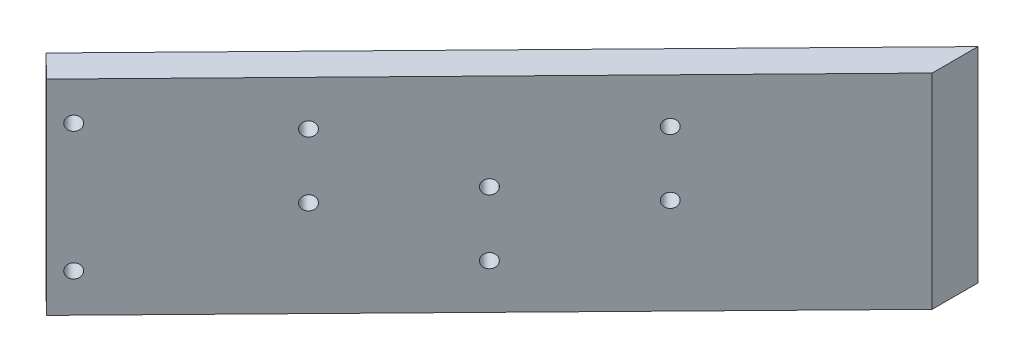
from build123d import *

# Parameters (mm, degrees)
BOSS_EXTRUDE1_DEPTH = 32
FILLET1_R           = 10
SKETCH4_W           = 170.11041037
SKETCH4_H           = 258.008077424
CUT_EXTRUDE2_DEPTH  = 33
SKETCH6_R           = 1.1
CUT_EXTRUDE3_DEPTH  = 54.954614149
SKETCH7_R           = 1.1
CUT_EXTRUDE4_DEPTH  = 57.514129524


with BuildPart() as part:
    # Sketch1 → Boss-Extrude1 (new body)
    with BuildSketch(Plane(origin=(0, 0, 0), x_dir=(1, 0, 0), z_dir=(0, 1, 0))):
        Polygon((0, 0), (0, 30), (83, 115), (83, 107.843231513), (5, 27.963713441), (5, -27.963713441), (83, -107.843231513), (83, -115), (0, -30), align=None)
    extrude(amount=BOSS_EXTRUDE1_DEPTH)

    # Fillet1
    fillet1_edges = [part.edges().sort_by_distance(p)[0] for p in [
        (0, 16, 30),
        (0, 16, -30),
    ]]
    fillet(fillet1_edges, radius=FILLET1_R)

    # Sketch4 → Cut-Extrude2 (cut, through all)
    with BuildSketch(Plane(origin=(0, 32, 0), x_dir=(1, 0, 0), z_dir=(0, 1, 0))):
        with Locations((35.635219957, -4.046970822)):
            Rectangle(SKETCH4_W, SKETCH4_H)
        Polygon((87.577370106, 112.530899694), (84, 116.024096386), (11, 41.265060241), (14.577370106, 37.771863549), align=None, mode=Mode.SUBTRACT)
    extrude(amount=-CUT_EXTRUDE2_DEPTH, mode=Mode.SUBTRACT)

    # Sketch6 → Cut-Extrude3 (cut, through all)
    with BuildSketch(Plane(origin=(-14.995748902, 0, -14.642907751), x_dir=(-0.698639338, 0, 0.715474021), z_dir=(-0.715474021, 0, -0.698639338))):
        with Locations((-40.209111306, 26)):
            Circle(SKETCH6_R)
        with Locations((-40.209111306, 6)):
            Circle(SKETCH6_R)
    extrude(amount=-CUT_EXTRUDE3_DEPTH, mode=Mode.SUBTRACT)

    # Sketch7 → Cut-Extrude4 (cut, through all)
    with BuildSketch(Plane(origin=(-11.418378796, 0, -11.14971106), x_dir=(0.698639338, 0, -0.715474021), z_dir=(0.715474021, 0, 0.698639338))):
        with Locations((66.177603446, 15)):
            Circle(SKETCH7_R)
        with Locations((66.177603446, 25)):
            Circle(SKETCH7_R)
        with Locations((106.177603446, 25)):
            Circle(SKETCH7_R)
        with Locations((106.177603446, 15)):
            Circle(SKETCH7_R)
        with Locations((86.177603446, 17)):
            Circle(SKETCH7_R)
        with Locations((86.177603446, 7)):
            Circle(SKETCH7_R)
    extrude(amount=-CUT_EXTRUDE4_DEPTH, mode=Mode.SUBTRACT)


solid = part.part
